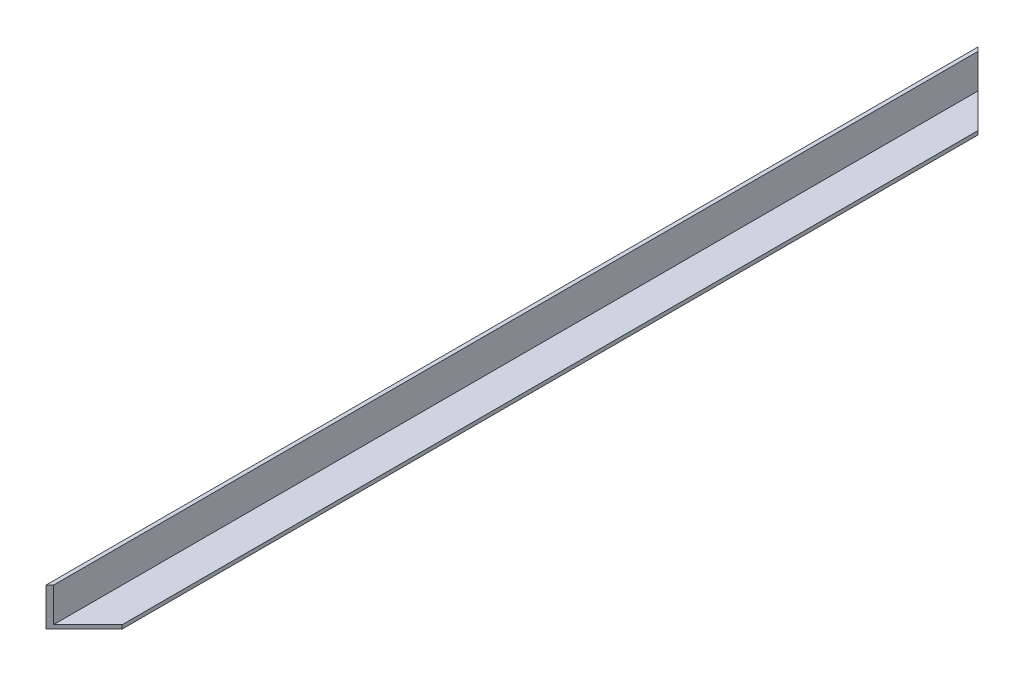
from build123d import *

# Parameters (mm, degrees)
BOSS_EXTRUDE1_DEPTH = 489
CUT_EXTRUDE2_DEPTH  = 485


with BuildPart() as part:
    # Sketch1 → Boss-Extrude1 (new body)
    with BuildSketch(Plane.XY):
        Polygon((0, 20), (0, 0), (20, 0), (20, 2), (2, 2), (2, 20), align=None)
    extrude(amount=BOSS_EXTRUDE1_DEPTH)

    # Sketch2 → Cut-Extrude2 (cut)
    with BuildSketch(Plane(origin=(0, 20, 0), x_dir=(1, 0, 0), z_dir=(0, 1, 0))):
        Polygon((2, 0), (0, 0), (2, -2), align=None)
        Polygon((2, 0), (2, -2), (20, -20), (20, 0), align=None)
        Polygon((2, -489), (2, -487), (0, -489), align=None)
        Polygon((20, -469), (2, -487), (2, -489), (20, -489), align=None)
    extrude(amount=-CUT_EXTRUDE2_DEPTH, mode=Mode.SUBTRACT)


solid = part.part
